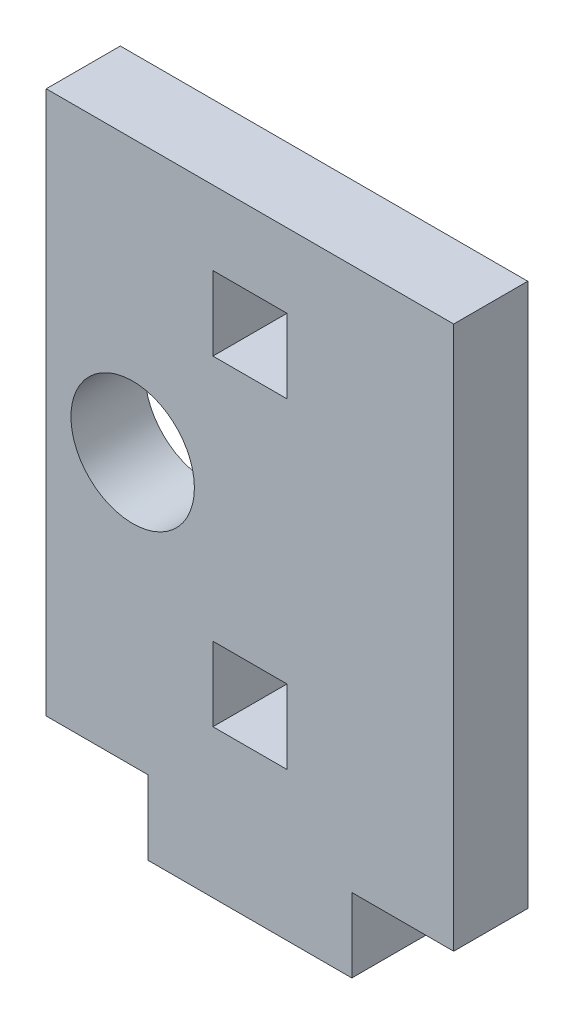
from build123d import *

# Parameters (mm, degrees)
SKETCH1_W           = 16.5
SKETCH1_H           = 22
BOSS_EXTRUDE1_DEPTH = 3
SKETCH2_W           = 8.25
SKETCH2_H           = 3
BOSS_EXTRUDE2_DEPTH = 3
SKETCH3_W           = 3
SKETCH3_H           = 3
CUT_EXTRUDE1_DEPTH  = 3
SKETCH4_R           = 2.5
CUT_EXTRUDE2_DEPTH  = 3


with BuildPart() as part:
    # Sketch1 → Boss-Extrude1 (new body)
    with BuildSketch(Plane.XY):
        Rectangle(SKETCH1_W, SKETCH1_H)
    extrude(amount=BOSS_EXTRUDE1_DEPTH)

    # Sketch2 → Boss-Extrude2 (add)
    with BuildSketch(Plane(origin=(0, -11, 0), x_dir=(-1, 0, 0), z_dir=(0, -1, 0))):
        with Locations((0, -1.5)):
            Rectangle(SKETCH2_W, SKETCH2_H)
    extrude(amount=BOSS_EXTRUDE2_DEPTH)

    # Sketch3 → Cut-Extrude1 (cut)
    with BuildSketch(Plane.XY.offset(3)):
        with Locations((0, 6.5)):
            Rectangle(SKETCH3_W, SKETCH3_H)
        with Locations((0, -6.5)):
            Rectangle(SKETCH3_W, SKETCH3_H)
    extrude(amount=-CUT_EXTRUDE1_DEPTH, mode=Mode.SUBTRACT)

    # Sketch4 → Cut-Extrude2 (cut)
    with BuildSketch(Plane.XY.offset(3)):
        with Locations((-4.75, 0)):
            Circle(SKETCH4_R)
    extrude(amount=-CUT_EXTRUDE2_DEPTH, mode=Mode.SUBTRACT)


solid = part.part
